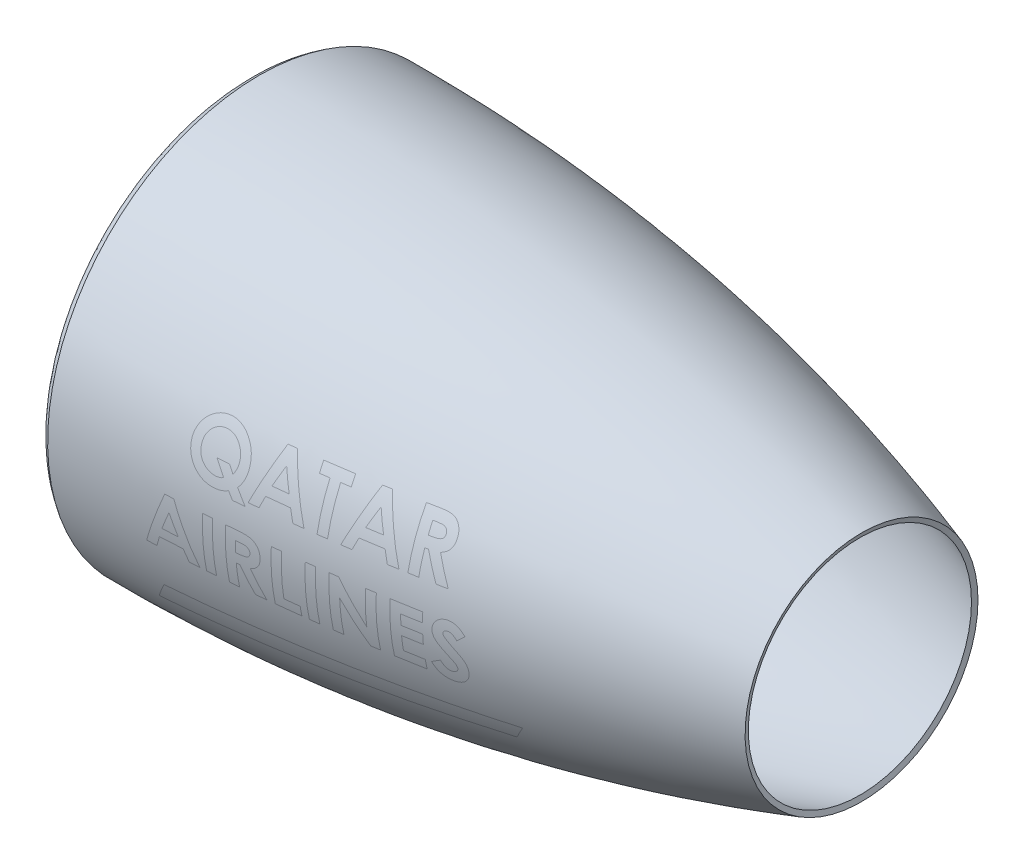
from build123d import *

# Parameters (mm, degrees)
THICKEN1_T1 = 5


with BuildPart() as body_1:
    # Surface-Revolve1: a surface, the sketch's curves turned about an axis
    with BuildLine(Plane.XY, mode=Mode.PRIVATE) as surface_revolve1_1_path:
        Line((54.695253386, 190), (29.695253386, 190))
        Line((29.695253386, 190), (25, 180))
        Line((25, 180), (0, 180))
        add(Edge.make_bspline(
            [(0, 180), (-14.563586633, 191.160033572), (0, 200)],
            knots=[0, 0, 0, 1, 1, 1], degree=2))
        add(Edge.make_bspline(
            [(0, 200), (297.75113242, 201.514028855), (580, 108)],
            knots=[0, 0, 0, 1, 1, 1], degree=2))
    surface_revolve1_1 = Shell.revolve(surface_revolve1_1_path.wire(), 360, Axis((0, 0, 0), (1, 0, 0)))
    add(Solid.thicken(surface_revolve1_1, THICKEN1_T1))


solid = body_1.part
